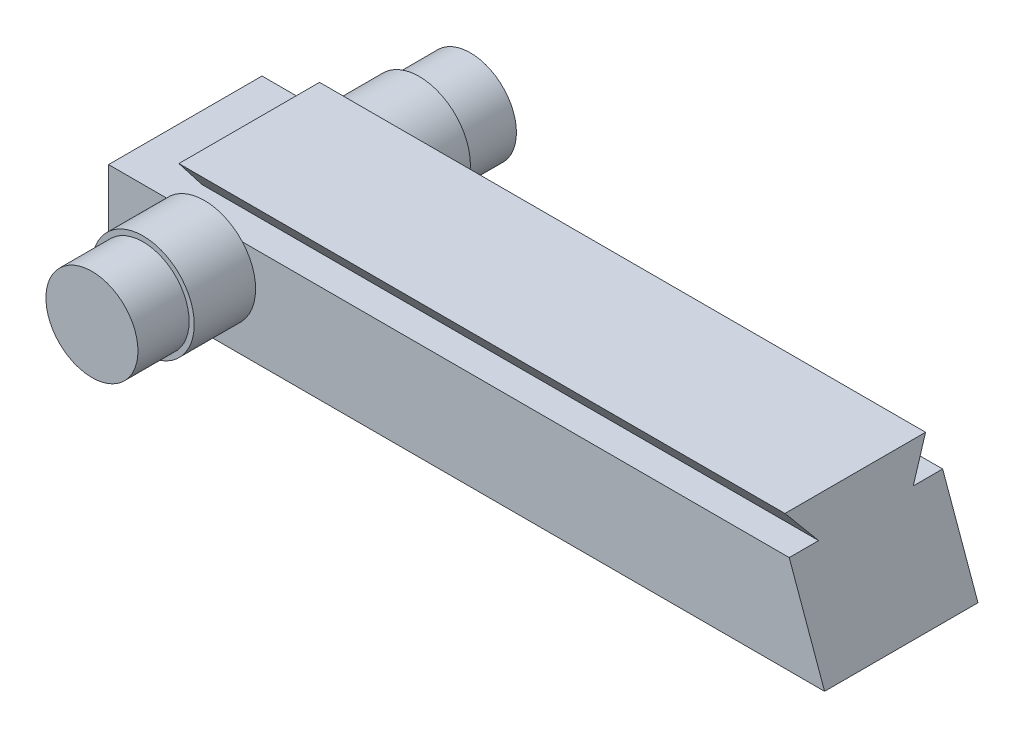
from build123d import *

# Parameters (mm, degrees)
SKETCH1_W           = 7.62
SKETCH1_H           = 4.8768
BOSS_EXTRUDE1_DEPTH = 17.78
BOSS_EXTRUDE2_DEPTH = 32.385
CUT_EXTRUDE1_DEPTH  = 8.62
SKETCH5_R           = 2.54
BOSS_EXTRUDE3_DEPTH = 3.048
SKETCH7_R           = 2.286
BOSS_EXTRUDE4_DEPTH = 2.54


with BuildPart() as part:
    # Sketch1 → Boss-Extrude1 (new body, symmetric)
    with BuildSketch(Plane(origin=(0, 0, 0), x_dir=(0, 0, -1), z_dir=(1, 0, 0))):
        Rectangle(SKETCH1_W, SKETCH1_H)
    extrude(amount=BOSS_EXTRUDE1_DEPTH, both=True)

    # Sketch2 → Boss-Extrude2 (add)
    with BuildSketch(Plane(origin=(17.78, 0, 0), x_dir=(0, 0, -1), z_dir=(1, 0, 0))):
        Polygon((-3.4925, 3.9116), (3.4925, 3.9116), (2.3495, 2.4384), (-2.3495, 2.4384), align=None)
    extrude(amount=-BOSS_EXTRUDE2_DEPTH)

    # Sketch3 → Cut-Extrude1 (cut, through all)
    with BuildSketch(Plane.XY.offset(3.81)):
        Polygon((17.78, -2.4384), (15.494, 3.9116), (17.78, 3.9116), align=None)
    extrude(amount=-CUT_EXTRUDE1_DEPTH, mode=Mode.SUBTRACT)

    # Sketch5 → Boss-Extrude3 (add)
    with BuildSketch(Plane.XY.offset(3.81)):
        with Locations((-13.0175, 0.7366)):
            Circle(SKETCH5_R)
    boss_extrude3 = extrude(amount=BOSS_EXTRUDE3_DEPTH)

    # Sketch7 → Boss-Extrude4 (add)
    with BuildSketch(Plane.XY.offset(6.858)):
        with Locations((-13.0175, 0.7366)):
            Circle(SKETCH7_R)
    boss_extrude4 = extrude(amount=BOSS_EXTRUDE4_DEPTH)

    # Mirror1: Boss-Extrude3, Boss-Extrude4 across plane
    add(boss_extrude3.mirror(Plane.XY))
    add(boss_extrude4.mirror(Plane.XY))


solid = part.part
